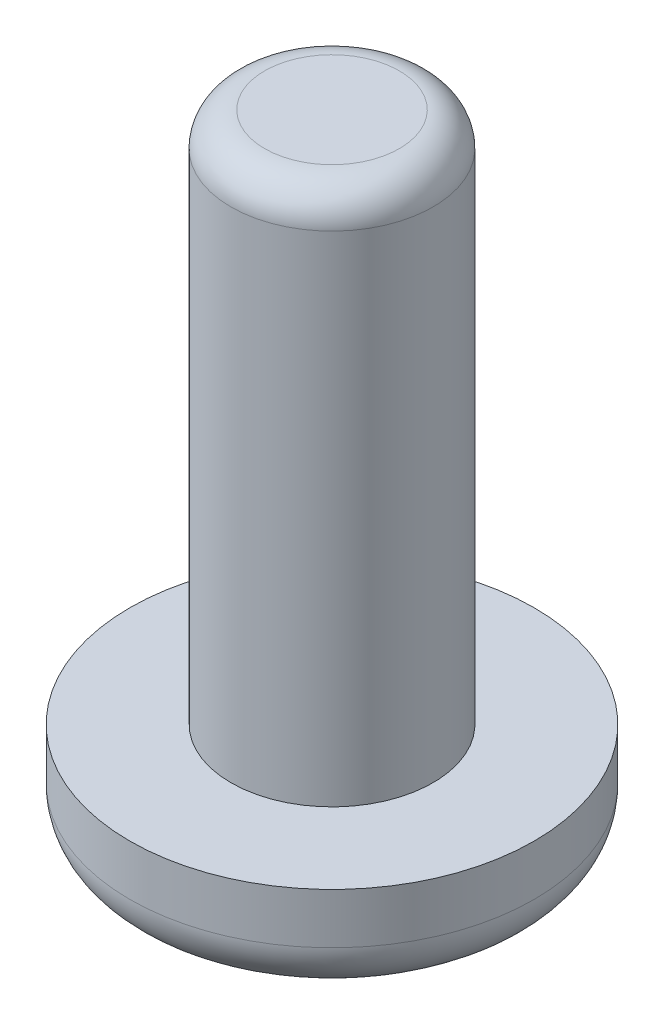
from build123d import *

# Parameters (mm, degrees)
SKETCH_1_R      = 6
EXTRUDE_1_DEPTH = 3
SKETCH_2_R      = 3
EXTRUDE_2_DEPTH = 15.8
FILLET_1_R      = 1
FILLET_2_R      = 1.5


with BuildPart() as part:
    # ｽｹｯﾁ1 → ﾎﾞｽ - 押し出し1 (new body)
    with BuildSketch(Plane(origin=(0, 0, 0), x_dir=(1, 0, 0), z_dir=(0, 1, 0))):
        Circle(SKETCH_1_R)
    extrude(amount=EXTRUDE_1_DEPTH)

    # ｽｹｯﾁ2 → ﾎﾞｽ - 押し出し2 (add)
    with BuildSketch(Plane(origin=(0, 3, 0), x_dir=(1, 0, 0), z_dir=(0, 1, 0))):
        Circle(SKETCH_2_R)
    extrude(amount=EXTRUDE_2_DEPTH)

    # ﾌｨﾚｯﾄ1
    fillet_1_edges = [part.edges().sort_by_distance(p)[0] for p in [
        (-3, 18.8, 0),
    ]]
    fillet(fillet_1_edges, radius=FILLET_1_R)

    # ﾌｨﾚｯﾄ2
    fillet_2_edges = [part.edges().sort_by_distance(p)[0] for p in [
        (-6, 0, 0),
    ]]
    fillet(fillet_2_edges, radius=FILLET_2_R)


solid = part.part
